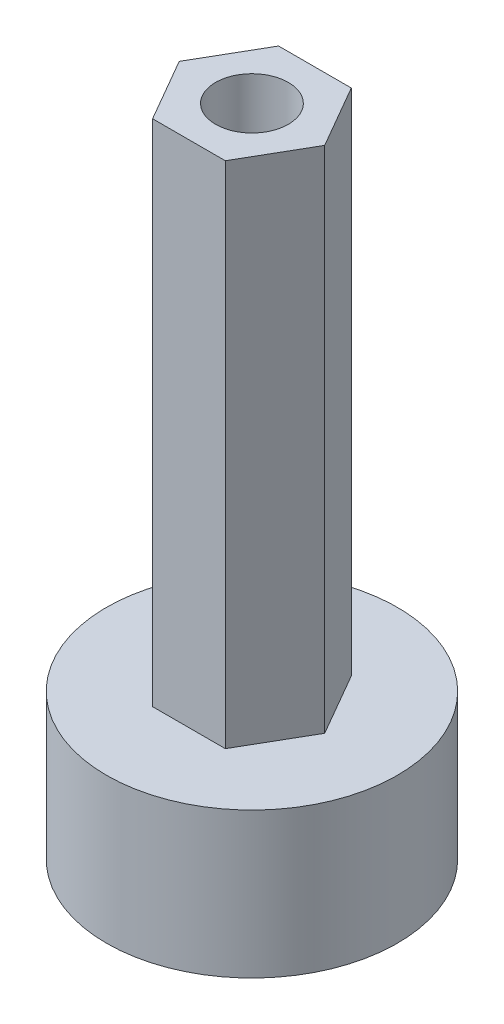
from build123d import *

# Parameters (mm, degrees)
CUT_EXTRUDE3_DEPTH = 22.225
SKETCH4_R          = 3.175
CUT_EXTRUDE4_DEPTH = 3.175


with BuildPart() as part:
    # Sketch2 → Revolve1 (revolve)
    with BuildSketch(Plane.XY):
        Polygon((6.35, 0), (6.35, 6.35), (3.175, 6.35), (3.175, 28.575), (1.5875, 28.575), (1.5875, 3.175), (3.175, 3.175), (3.175, 0), align=None)
    revolve(axis=Axis((0, 41.227012609, 0), (0, -1, 0)))

    # Sketch3 → Cut-Extrude3 (cut)
    with BuildSketch(Plane(origin=(0, 28.575, 0), x_dir=(1, 0, 0), z_dir=(0, 1, 0))):
        with BuildLine():
            Line((-3.175, 0), (-1.5875, 2.749630657))
            ThreePointArc((-1.5875, 2.749630657), (-2.749630657, 1.5875), (-3.175, 0))
        make_face()
        with BuildLine():
            ThreePointArc((1.5875, 2.749630657), (0, 3.175), (-1.5875, 2.749630657))
            Line((-1.5875, 2.749630657), (1.5875, 2.749630657))
        make_face()
        with BuildLine():
            ThreePointArc((3.175, 0), (2.749630657, 1.5875), (1.5875, 2.749630657))
            Line((1.5875, 2.749630657), (3.175, 0))
        make_face()
        with BuildLine():
            ThreePointArc((1.5875, -2.749630657), (2.749630657, -1.5875), (3.175, 0))
            Line((3.175, 0), (1.5875, -2.749630657))
        make_face()
        with BuildLine():
            Line((1.5875, -2.749630657), (-1.5875, -2.749630657))
            ThreePointArc((-1.5875, -2.749630657), (0, -3.175), (1.5875, -2.749630657))
        make_face()
        with BuildLine():
            Line((-1.5875, -2.749630657), (-3.175, 0))
            ThreePointArc((-3.175, 0), (-2.749630657, -1.5875), (-1.5875, -2.749630657))
        make_face()
    extrude(amount=-CUT_EXTRUDE3_DEPTH, mode=Mode.SUBTRACT)

    # Sketch4 → Cut-Extrude4 (cut)
    with BuildSketch(Plane.XZ):
        with BuildLine():
            ThreePointArc((-2.74963064, 1.58750003), (-1.587499985, 2.749630666), (0, 3.175))
            Line((0, 3.175), (-1.833087105, 3.175))
            Line((-1.833087105, 3.175), (-2.74963064, 1.58750003))
        make_face()
        with BuildLine():
            Line((2.749630611, 1.58750008), (1.833087105, 3.175))
            Line((1.833087105, 3.175), (0, 3.175))
            ThreePointArc((0, 3.175), (1.58749996, 2.74963068), (2.749630611, 1.58750008))
        make_face()
        with BuildLine():
            Line((3.666174209, 0), (2.749630611, 1.58750008))
            ThreePointArc((2.749630611, 1.58750008), (3.066814486, 0.821750513), (3.175, 0))
            ThreePointArc((3.175, 0), (3.066814483, -0.821750528), (2.749630596, -1.587500106))
            Line((2.749630596, -1.587500106), (3.666174209, 0))
        make_face()
        with BuildLine():
            Line((1.833087105, -3.175), (2.749630596, -1.587500106))
            ThreePointArc((2.749630596, -1.587500106), (1.587499947, -2.749630688), (0, -3.175))
            Line((0, -3.175), (1.833087105, -3.175))
        make_face()
        with BuildLine():
            ThreePointArc((0, -3.175), (-1.587499999, -2.749630657), (-2.749630656, -1.587500001))
            Line((-2.749630656, -1.587500001), (-1.833087105, -3.175))
            Line((-1.833087105, -3.175), (0, -3.175))
        make_face()
        with BuildLine():
            ThreePointArc((-2.749630656, -1.587500001), (-3.175, 1.7e-08), (-2.74963064, 1.58750003))
            Line((-2.74963064, 1.58750003), (-3.666174209, 0))
            Line((-3.666174209, 0), (-2.749630656, -1.587500001))
        make_face()
        Circle(SKETCH4_R)
    extrude(amount=-CUT_EXTRUDE4_DEPTH, mode=Mode.SUBTRACT)


solid = part.part
